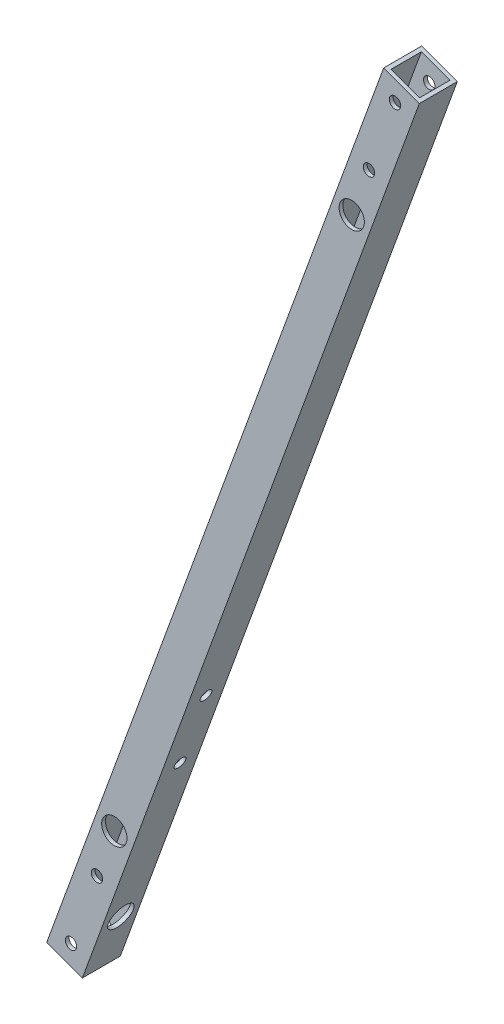
from build123d import *

# Parameters (mm, degrees)
EXTRUDE_1_DEPTH             = 15
SHELL_1_T                   = -1.5
SKETCH_3_R                  = 2.25
SKETCH_3_R_2                = 2.7
CUT_EXTRUDE_1_DEPTH         = 25
SKETCH_5_R                  = 2.25
SKETCH_5_R_2                = 2.7
CUT_EXTRUDE_3_DEPTH         = 20
HOLE_WIZARD_10_0_10_1_D     = 10
HOLE_WIZARD_10_0_10_1_DEPTH = 1.5
HOLE_WIZARD_10_0_10_2_D     = 10
HOLE_WIZARD_10_0_10_2_DEPTH = 1.5


with BuildPart() as part:
    # ｽｹｯﾁ1 → ﾎﾞｽ - 押し出し1 (new body)
    with BuildSketch(Plane.XY):
        Polygon((133.1152144, 365.731045751), (0, 0), (-14.095389312, 5.13030215), (119.019825089, 370.861347901), align=None)
    extrude(amount=EXTRUDE_1_DEPTH)

    # ｼｪﾙ1
    shell_1_openings = [part.faces().sort_by_distance(p)[0] for p in [
        (126.067519744, 368.296196826, 7.5),
        (-7.047694656, 2.565151075, 7.5),
    ]]
    offset(amount=SHELL_1_T, openings=shell_1_openings, kind=Kind.INTERSECTION)

    # ｽｹｯﾁ3 → ｶｯﾄ - 押し出し1 (cut)
    with BuildSketch(Plane.XY.offset(15)):
        with Locations((-4.482543581, 9.612845731)):
            Circle(SKETCH_3_R)
        with Locations((123.50236867, 361.24850217)):
            Circle(SKETCH_3_R)
        with Locations((113.24176437, 333.057723546)):
            Circle(SKETCH_3_R)
        with Locations((5.778060719, 37.803624354)):
            Circle(SKETCH_3_R)
        with Locations((12.618463585, 56.59747677)):
            Circle(SKETCH_3_R_2)
        with Locations((106.401361503, 314.263871131)):
            Circle(SKETCH_3_R_2)
    extrude(amount=-CUT_EXTRUDE_1_DEPTH, mode=Mode.SUBTRACT)

    # ｽｹｯﾁ5 → ｶｯﾄ - 押し出し3 (cut)
    with BuildSketch(Plane(origin=(-14.095389312, 5.13030215, 0), x_dir=(0, 0, 1), z_dir=(-0.939692621, 0.342020143, 0))):
        with Locations((7.5, 120.877716811)):
            Circle(SKETCH_5_R)
        with Locations((7.5, 90.877716811)):
            Circle(SKETCH_5_R)
        with Locations((7.5, 22.5)):
            Circle(SKETCH_5_R_2)
    extrude(amount=-CUT_EXTRUDE_3_DEPTH, mode=Mode.SUBTRACT)

    # Ø10.0 (10) 直径の穴1
    with Locations(Plane(origin=(0, 0, 0), x_dir=(0, 0, -1), z_dir=(0.939692621, -0.342020143, 0))):
        with Locations((-7.5, 22.5)):
            Hole(HOLE_WIZARD_10_0_10_1_D / 2, depth=HOLE_WIZARD_10_0_10_1_DEPTH)

    # Ø10.0 (10) 直径の穴2
    with Locations(Plane.XY.offset(15)):
        with Locations((106.401361503, 314.263871131), (12.618463585, 56.59747677)):
            Hole(HOLE_WIZARD_10_0_10_2_D / 2, depth=HOLE_WIZARD_10_0_10_2_DEPTH)


solid = part.part
